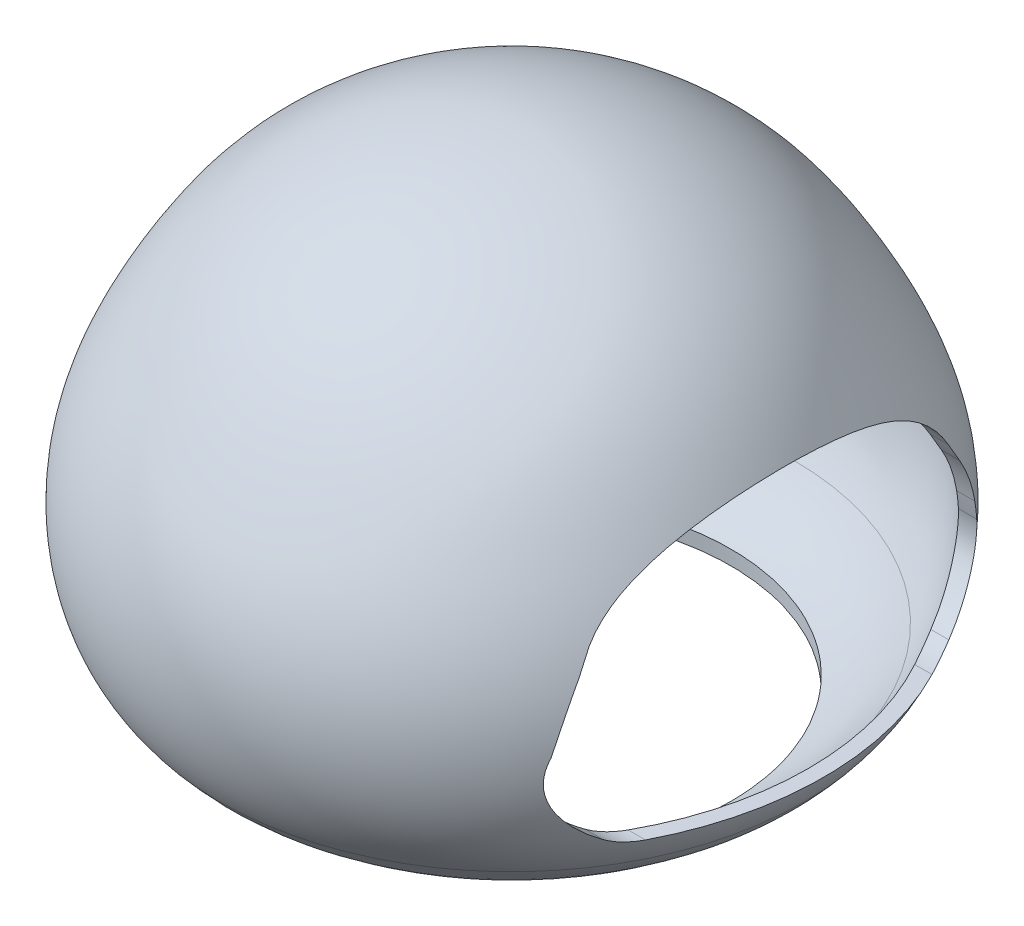
from build123d import *

# Parameters (mm, degrees)
SKETCH4_R           = 80.100145108
CUT_EXTRUDE2_DEPTH  = 20
CUT_EXTRUDE3_DEPTH  = 121.706010599
BOSS_EXTRUDE1_REACH = 54.085
SKETCH6_R           = 10


with BuildPart() as part:
    # Sketch3 → Revolve5 (revolve)
    with BuildSketch(Plane.XY):
        with BuildLine():
            Line((0.02453969, 157.084900749), (0.02453969, 152.084900749))
            add(Edge.make_bspline(
                [(-103.174583613, -2.6432e-05), (-114.760245555, 14.576189089), (-119.836740195, 49.27275863), (-101.45175109, 88.673946708), (-71.379831841, 134.479430747), (-29.75001244, 152.084900749), (0.02453969, 152.084900749)],
                knots=[0, 0, 0, 0, 0.250738493, 0.442513363, 0.587644713, 1, 1, 1, 1], degree=3))
            add(Edge.make_bspline(
                [(-103.174583613, -2.6432e-05), (-78.832759046, -30.064140021), (-33.458723298, -20.943389124), (0.02453969, -20.943389124)],
                knots=[0, 0, 0, 0, 1, 1, 1, 1], degree=3))
            Line((0.02453969, -20.943389124), (0.02453969, -25.943389124))
            add(Edge.make_bspline(
                [(0.02453969, -25.943389124), (-1.007843071, -25.943389124), (-3.05274325, -25.960735741), (-7.300680211, -26.054029266), (-12.774839269, -26.259816275), (-19.586870399, -26.581007249), (-28.911339242, -27.014332449), (-40.900445748, -27.386982651), (-55.443773123, -26.975342887), (-69.789912797, -25.08625158), (-81.278725906, -21.722461367), (-89.959801918, -17.60281584), (-96.13825684, -13.717797758), (-100.945853349, -9.752185194), (-104.534382709, -6.13029221), (-106.254478554, -4.141899361), (-107.07473695, -3.128814187)],
                knots=[-0.000194385, -0.000194385, -0.000194385, -0.000194385, 0.03106169, 0.062317764, 0.124829913, 0.187342062, 0.249854211, 0.37487851, 0.499902808, 0.624927106, 0.749951404, 0.812463553, 0.874975702, 0.937487851, 0.968743925, 1, 1, 1, 1], degree=3))
            add(Edge.make_bspline(
                [(-107.07473695, -3.128814187), (-107.861659129, -2.138767408), (-109.375579618, -0.100482773), (-112.095489807, 4.115600278), (-114.955951775, 9.644100323), (-117.55365357, 16.585319153), (-119.962688147, 26.134623726), (-121.103112226, 38.406473215), (-119.79356064, 53.088411426), (-116.089945574, 67.047457773), (-110.633897624, 80.23296506), (-104.034329909, 92.718986198), (-96.815301706, 104.751602155), (-88.512248671, 116.246845317), (-78.667704424, 126.697829164), (-67.464684594, 135.71357688), (-55.182594106, 143.280590712), (-42.054195525, 149.310974483), (-28.321126938, 153.731407172), (-14.204212291, 156.457352496), (-4.722534611, 157.084900749), (0.02453969, 157.084900749)],
                knots=[-0.000101258, -0.000101258, -0.000101258, -0.000101258, 0.015525324, 0.031151906, 0.06240507, 0.093658235, 0.124911399, 0.187417728, 0.249924056, 0.312430385, 0.374936714, 0.437443042, 0.499949371, 0.562455699, 0.624962028, 0.687468357, 0.749974685, 0.812481014, 0.874987343, 0.937493671, 1, 1, 1, 1], degree=3))
        make_face()
    revolve(axis=Axis((0.02453969, 171.610282588, 0), (0, -1, 0)))

    # Sketch4 → Cut-Extrude2 (cut)
    with BuildSketch(Plane(origin=(0, -30, 0), x_dir=(1, 0, 0), z_dir=(0, 1, 0))):
        Circle(SKETCH4_R)
    extrude(amount=CUT_EXTRUDE2_DEPTH, mode=Mode.SUBTRACT)

    # Sketch5 → Cut-Extrude3 (cut, through all)
    with BuildSketch(Plane(origin=(0, 0, 0), x_dir=(0, 0, -1), z_dir=(1, 0, 0))):
        with BuildLine():
            Line((-52.476481645, 8.136577936), (52.476481645, 8.136577936))
            ThreePointArc((52.476481645, 8.136577936), (58.138069368, 8.954648303), (63.336499377, 11.341935492))
            add(Edge.make_bspline(
                [(63.336499377, 11.341935492), (82.622361185, 23.812864951), (78.746201445, 39.317958114)],
                knots=[5.637022825, 5.637022825, 5.637022825, 6.404500867, 6.404500867, 6.404500867], degree=2, weights=[1, 0.927271268, 1]))
            ThreePointArc((78.746201445, 39.317958114), (77.929706658, 42.769255575), (77.20089719, 46.240127895))
            add(Edge.make_bspline(
                [(70.494135614, 63.047069033), (72.356334923, 60.10156835), (75.045149162, 54.673263207), (76.692738831, 48.822390655), (77.20089719, 46.240127895)],
                knots=[0.168181527, 0.168181527, 0.168181527, 0.168181527, 0.552818848, 0.845617793, 0.845617793, 0.845617793, 0.845617793], degree=3))
            ThreePointArc((70.494135614, 63.047069033), (68.293855497, 66.646255249), (66.203011989, 70.31009851))
            add(Edge.make_bspline(
                [(66.203011989, 70.31009851), (-4.427969211, 198.528374497), (-67.022107814, 68.723719713)],
                knots=[0.328274459, 0.328274459, 0.328274459, 2.851830568, 2.851830568, 2.851830568], degree=2, weights=[1, 0.304123557, 1]))
            ThreePointArc((-67.022107814, 68.723719713), (-68.159373057, 66.423614108), (-69.341813393, 64.146402461))
            add(Edge.make_bspline(
                [(-69.341813393, 64.146402461), (-73.061653072, 57.152172395), (-75.898874077, 49.79082496), (-77.836559233, 42.105665134)],
                knots=[0.114274397, 0.114274397, 0.114274397, 0.114274397, 1, 1, 1, 1], degree=3))
            add(Edge.make_bspline(
                [(-77.836559233, 42.105665134), (-84.680776254, 25.143909909), (-63.336499377, 11.341935492)],
                knots=[2.947295522, 2.947295522, 2.947295522, 3.787755136, 3.787755136, 3.787755136], degree=2, weights=[1, 0.91299521, 1]))
            ThreePointArc((-63.336499377, 11.341935492), (-58.138069368, 8.954648303), (-52.476481645, 8.136577936))
        make_face()
    extrude(amount=CUT_EXTRUDE3_DEPTH, mode=Mode.SUBTRACT)

    # Sketch6 → Boss-Extrude1 (add, up to next)
    with BuildSketch(Plane(origin=(0, 105, 0), x_dir=(1, 0, 0), z_dir=(0, 1, 0)), mode=Mode.PRIVATE) as boss_extrude1_sk1:
        Circle(SKETCH6_R)
    boss_extrude1_tool1 = extrude(boss_extrude1_sk1.sketch, amount=BOSS_EXTRUDE1_REACH, mode=Mode.PRIVATE) - part.part
    add(boss_extrude1_tool1.solids().sort_by_distance((0, 105, 0))[0])


solid = part.part
